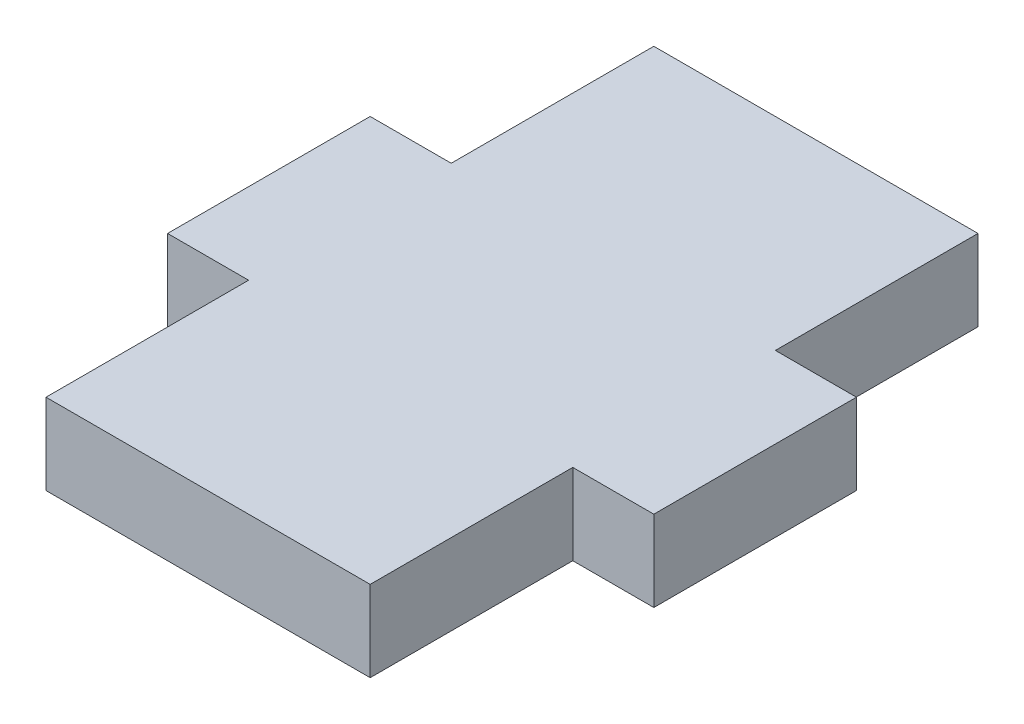
from build123d import *

# Parameters (mm, degrees)
SZKIC1_W                    = 8
SZKIC1_H                    = 1.995325655
DODANIE_WYCI_GNI_CIE1_DEPTH = 15
SZKIC3_W                    = 5
SZKIC3_H                    = 1.995325655
DODANIE_WYCI_GNI_CIE2_DEPTH = 2
SZKIC5_W                    = 5
SZKIC5_H                    = 1.995325655
DODANIE_WYCI_GNI_CIE3_DEPTH = 2


with BuildPart() as part:
    # Szkic1 → Dodanie-wyciągnięcie1 (new body)
    with BuildSketch(Plane.XY):
        with Locations((-4, -374.322437992)):
            Rectangle(SZKIC1_W, SZKIC1_H)
    extrude(amount=-DODANIE_WYCI_GNI_CIE1_DEPTH)

    # Szkic3 → Dodanie-wyciągnięcie2 (add)
    with BuildSketch(Plane.ZY.offset(8)):
        with Locations((-7.5, -374.322437992)):
            Rectangle(SZKIC3_W, SZKIC3_H)
    extrude(amount=DODANIE_WYCI_GNI_CIE2_DEPTH)

    # Szkic5 → Dodanie-wyciągnięcie3 (add)
    with BuildSketch(Plane(origin=(0, 0, 0), x_dir=(0, 0, -1), z_dir=(1, 0, 0))):
        with Locations((7.5, -374.322437992)):
            Rectangle(SZKIC5_W, SZKIC5_H)
    extrude(amount=DODANIE_WYCI_GNI_CIE3_DEPTH)


solid = part.part
